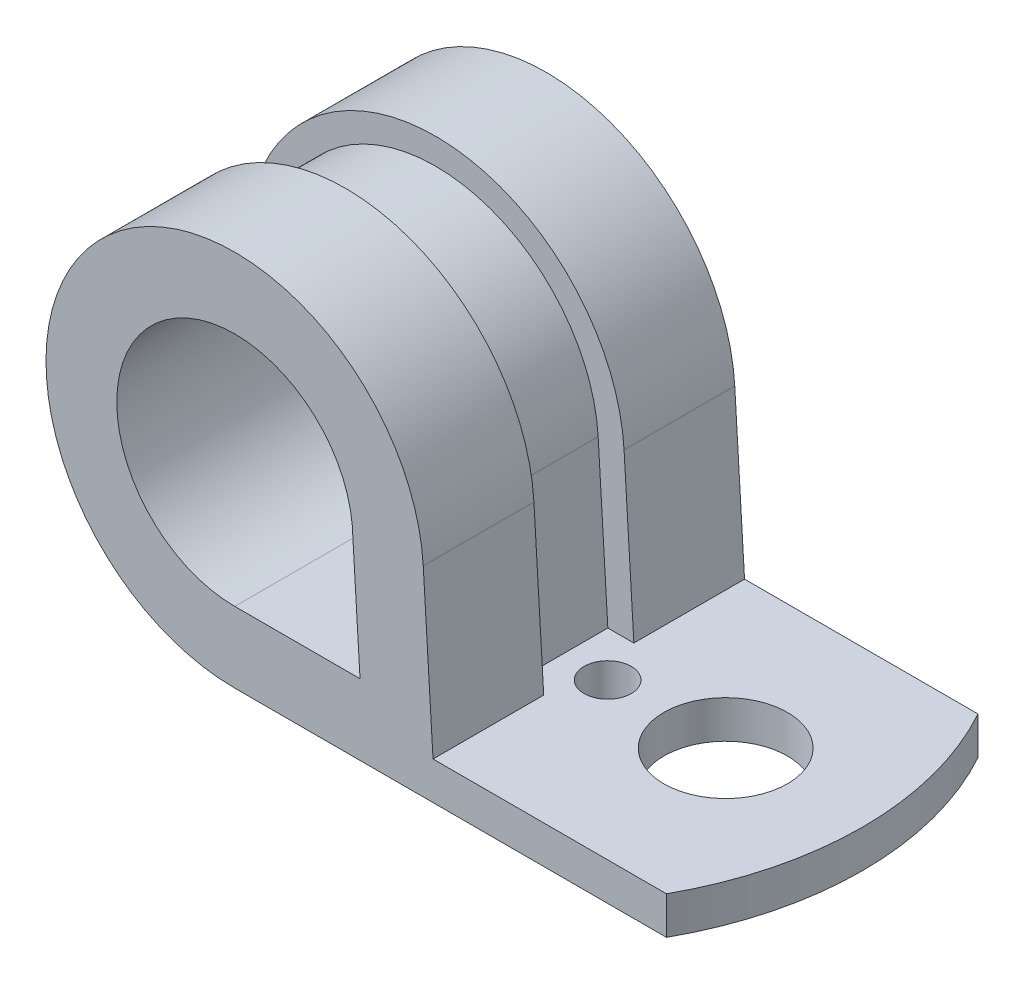
from build123d import *

# Parameters (mm, degrees)
BOSS_EXTRUDE1_DEPTH = 8.382
CUT_EXTRUDE2_DEPTH  = 2.032
SKETCH4_R           = 3.3274
SKETCH4_R_2         = 1.27
CUT_EXTRUDE3_DEPTH  = 3.032
CUT_EXTRUDE4_DEPTH  = 2.4257


with BuildPart() as part:
    # Sketch1 → Boss-Extrude1 (new body, symmetric)
    with BuildSketch(Plane.XY):
        with BuildLine():
            Line((0, 0), (-25.4, 0))
            ThreePointArc((-25.4, 0), (-32.797029365, 17.124880227), (-15.258381189, 10.77087469))
            Line((-15.258381189, 10.77087469), (-14.732, 2.032))
            Line((-14.732, 2.032), (0, 2.032))
            Line((0, 2.032), (0, 0))
        make_face()
        with BuildLine():
            Line((-25.4, 3.81), (-18.660167236, 3.81))
            Line((-18.660167236, 3.81), (-19.079451597, 10.77087469))
            ThreePointArc((-19.079451597, 10.77087469), (-30.101146364, 14.428691001), (-25.4, 3.81))
        make_face(mode=Mode.SUBTRACT)
    extrude(amount=BOSS_EXTRUDE1_DEPTH, both=True)

    # Sketch3 → Cut-Extrude2 (cut)
    with BuildSketch(Plane(origin=(0, 2.032, 0), x_dir=(1, 0, 0), z_dir=(0, 1, 0))):
        with BuildLine():
            Line((0, -8.382), (0, 0))
            ThreePointArc((0, 0), (-0.55079832, -4.328930418), (-2.168093689, -8.382))
            Line((-2.168093689, -8.382), (0, -8.382))
        make_face()
        with BuildLine():
            Line((0, 0), (0, 8.382))
            Line((0, 8.382), (-2.168093689, 8.382))
            ThreePointArc((-2.168093689, 8.382), (-0.55079832, 4.328930418), (0, 0))
        make_face()
    extrude(amount=-CUT_EXTRUDE2_DEPTH, mode=Mode.SUBTRACT)

    # Sketch4 → Cut-Extrude3 (cut, through all)
    with BuildSketch(Plane(origin=(0, 2.032, 0), x_dir=(1, 0, 0), z_dir=(0, 1, 0))):
        with Locations((-7.366, 0)):
            Circle(SKETCH4_R)
        with Locations((-13.716, 0)):
            Circle(SKETCH4_R_2)
    extrude(amount=-CUT_EXTRUDE3_DEPTH, mode=Mode.SUBTRACT)

    # Sketch5 → Cut-Extrude4 (cut, symmetric)
    with BuildSketch(Plane.XY):
        with BuildLine():
            Line((-25.4, 0), (-18.430674034, 0))
            Line((-18.430674034, 0), (-18.514821541, 1.397))
            Line((-18.514821541, 1.397), (-25.4, 1.397))
            ThreePointArc((-25.4, 1.397), (-31.779937827, 16.167209196), (-16.652853775, 10.68687942))
            Line((-16.652853775, 10.68687942), (-16.131531994, 2.032))
            Line((-16.131531994, 2.032), (-14.732, 2.032))
            Line((-14.732, 2.032), (-15.258381189, 10.77087469))
            ThreePointArc((-15.258381189, 10.77087469), (-32.797029365, 17.124880227), (-25.4, 0))
        make_face()
    extrude(amount=CUT_EXTRUDE4_DEPTH, both=True, mode=Mode.SUBTRACT)


solid = part.part
